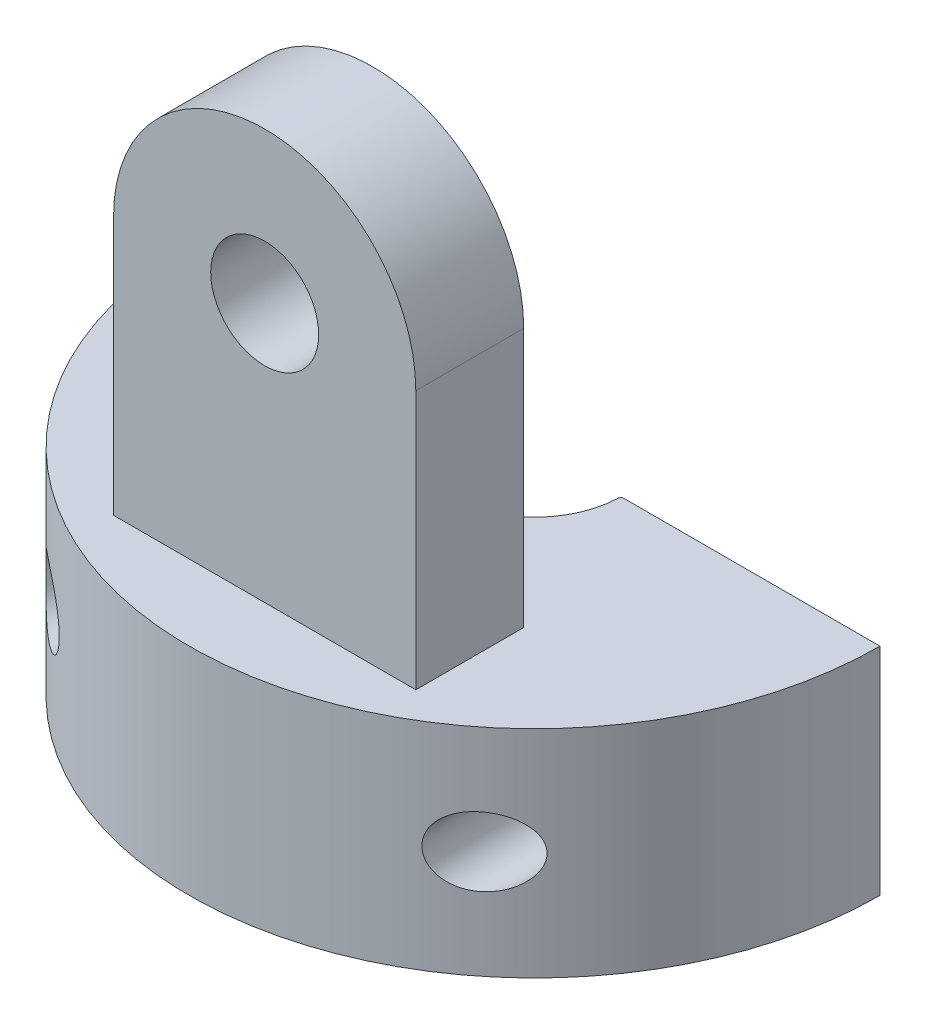
from build123d import *

# Parameters (mm, degrees)
BOSS_EXTRUDE1_DEPTH   = 2.5
SKETCH2_W             = 7
SKETCH2_H             = 2.5
BOSS_EXTRUDE2_DEPTH   = 9.5
CUT_EXTRUDE1_DEPTH    = 9.5
SKETCH4_R             = 1.25
CUT_EXTRUDE2_DEPTH    = 9.5
M2X0_4_TAPPED_HOLE1_D = 1.6
FILLET1_R             = 0.07


with BuildPart() as part:
    # Sketch1 → Boss-Extrude1 (new body, symmetric)
    with BuildSketch(Plane(origin=(0, 0, 0), x_dir=(1, 0, 0), z_dir=(0, 1, 0))):
        with BuildLine():
            Line((2, 0), (8, 0))
            ThreePointArc((8, 0), (0, -8), (-8, 0))
            Line((-8, 0), (-2, 0))
            ThreePointArc((-2, 0), (0, -2), (2, 0))
        make_face()
    extrude(amount=BOSS_EXTRUDE1_DEPTH, both=True)

    # Sketch2 → Boss-Extrude2 (add)
    with BuildSketch(Plane(origin=(0, 2.5, 0), x_dir=(1, 0, 0), z_dir=(0, 1, 0))):
        with Locations((0, -5)):
            Rectangle(SKETCH2_W, SKETCH2_H)
    extrude(amount=BOSS_EXTRUDE2_DEPTH)

    # Sketch3 → Cut-Extrude1 (cut)
    with BuildSketch(Plane(origin=(0, 0, 3.75), x_dir=(-1, 0, 0), z_dir=(0, 0, -1))):
        with BuildLine():
            Line((-3.5, 8.5), (-3.5, 14.886359519))
            Line((-3.5, 14.886359519), (0, 16.809201746))
            Line((0, 16.809201746), (3.5, 14.5))
            Line((3.5, 14.5), (3.5, 8.5))
            ThreePointArc((3.5, 8.5), (0, 12), (-3.5, 8.5))
        make_face()
    extrude(amount=-CUT_EXTRUDE1_DEPTH, mode=Mode.SUBTRACT)

    # Sketch4 → Cut-Extrude2 (cut)
    with BuildSketch(Plane(origin=(0, 0, 3.75), x_dir=(-1, 0, 0), z_dir=(0, 0, -1))):
        with Locations((0, 8.5)):
            Circle(SKETCH4_R)
    extrude(amount=-CUT_EXTRUDE2_DEPTH, mode=Mode.SUBTRACT)

    # M2x0.4 Tapped Hole1 (through all)
    with Locations(Plane(origin=(0, 0, 0), x_dir=(-1, 0, 0), z_dir=(0, 0, -1))):
        with Locations((-5, 0), (5, 0)):
            Hole(M2X0_4_TAPPED_HOLE1_D / 2)

    # Fillet1
    fillet1_edges = [part.edges().sort_by_distance(p)[0] for p in [
        (2, 0, 0),
        (-2, 0, 0),
    ]]
    fillet(fillet1_edges, radius=FILLET1_R)


solid = part.part
